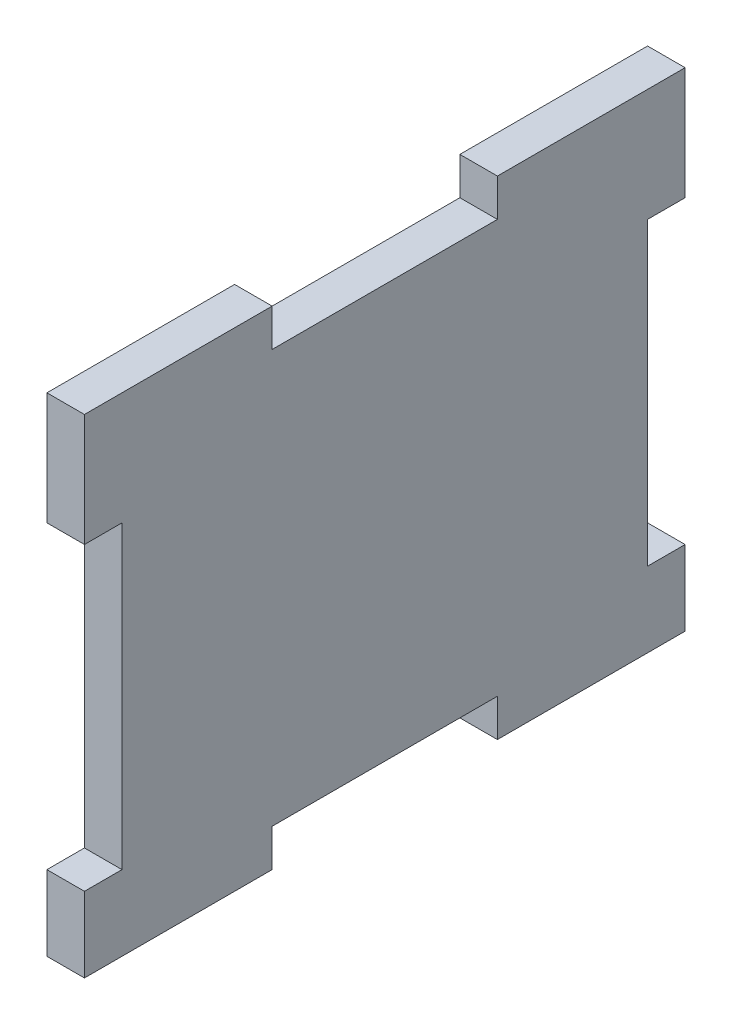
from build123d import *

# Parameters (mm, degrees)
BOSS_EXTRUDE1_DEPTH = 6.35


with BuildPart() as part:
    # Sketch1 → Boss-Extrude1 (new body)
    with BuildSketch(Plane(origin=(0, 0, 0), x_dir=(0, 0, -1), z_dir=(1, 0, 0))):
        Polygon((-50.8, -28.575), (-50.8, -41.275), (-19.05, -41.275), (-19.05, -34.925), (19.05, -34.925), (19.05, -41.275), (50.8, -41.275), (50.8, -28.575), (44.45, -28.575), (44.45, 22.225), (50.8, 22.225), (50.8, 41.275), (19.05, 41.275), (19.05, 34.925), (-19.05, 34.925), (-19.05, 41.275), (-50.8, 41.275), (-50.8, 22.225), (-44.45, 22.225), (-44.45, -28.575), align=None)
    extrude(amount=BOSS_EXTRUDE1_DEPTH)


solid = part.part
